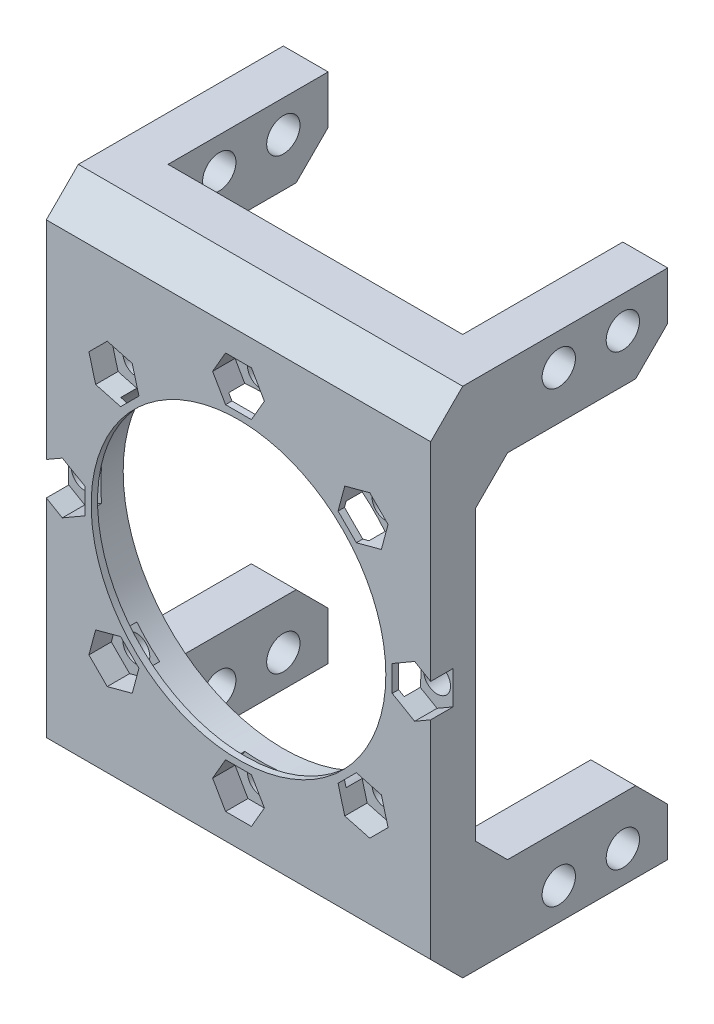
from build123d import *

# Parameters (mm, degrees)
SKETCH1_W               = 60
SKETCH1_H               = 80
BOSS_EXTRUDE1_DEPTH     = 7
SKETCH2_W               = 7
SKETCH2_H               = 12.5
BOSS_EXTRUDE2_DEPTH     = 30
SKETCH3_R               = 2.6
CUT_EXTRUDE1_DEPTH      = 50
SKETCH4_R               = 25
CUT_EXTRUDE2_DEPTH      = 107.625512894
SKETCH6_R               = 2.1
CUT_EXTRUDE3_DEPTH      = 107.625512894
MIRROR2_COPY_1_SKETCH_W = 7
MIRROR2_COPY_1_SKETCH_H = 12.5
MIRROR2_COPY_1_DEPTH    = 30
MIRROR2_COPY_2_SKETCH_R = 2.6
MIRROR2_COPY_2_DEPTH    = 50
CHAMFER1_SIZE           = 5
CHAMFER2_SIZE           = 5
SKETCH9_W               = 46
SKETCH9_H               = 7.5
BOSS_EXTRUDE4_DEPTH     = 5
CHAMFER3_SIZE           = 5
SKETCH20_R              = 25
SKETCH20_R_2            = 23
BOSS_EXTRUDE5_DEPTH     = 1
CUT_EXTRUDE5_DEPTH      = 3.5


with BuildPart() as part:
    # Sketch1 → Boss-Extrude1 (new body)
    with BuildSketch(Plane.XY):
        with Locations((30, 40)):
            Rectangle(SKETCH1_W, SKETCH1_H)
    extrude(amount=BOSS_EXTRUDE1_DEPTH)

    # Sketch2 → Boss-Extrude2 (add)
    with BuildSketch(Plane(origin=(0, 0, 0), x_dir=(-1, 0, 0), z_dir=(0, 0, -1))):
        with Locations((-3.5, 73.75)):
            Rectangle(SKETCH2_W, SKETCH2_H)
    boss_extrude2 = extrude(amount=BOSS_EXTRUDE2_DEPTH)

    # Sketch3 → Cut-Extrude1 (cut)
    with BuildSketch(Plane.ZY):
        with Locations((-13, 75)):
            Circle(SKETCH3_R)
        with Locations((-23, 75)):
            Circle(SKETCH3_R)
    cut_extrude1 = extrude(amount=-CUT_EXTRUDE1_DEPTH, mode=Mode.SUBTRACT)

    # Sketch4 → Cut-Extrude2 (cut, through all)
    with BuildSketch(Plane.XY.offset(7)):
        with Locations((30, 40)):
            Circle(SKETCH4_R)
    extrude(amount=-CUT_EXTRUDE2_DEPTH, mode=Mode.SUBTRACT)

    # Sketch6 → Cut-Extrude3 (cut, through all)
    with BuildSketch(Plane.XY.offset(7)):
        with Locations((30, 67.5)):
            Circle(SKETCH6_R)
        with Locations((49.445436483, 59.445436483)):
            Circle(SKETCH6_R)
        with Locations((57.5, 40)):
            Circle(SKETCH6_R)
        with Locations((49.445436483, 20.554563517)):
            Circle(SKETCH6_R)
        with Locations((30, 12.5)):
            Circle(SKETCH6_R)
        with Locations((10.554563517, 20.554563517)):
            Circle(SKETCH6_R)
        with Locations((2.5, 40)):
            Circle(SKETCH6_R)
        with Locations((10.554563517, 59.445436483)):
            Circle(SKETCH6_R)
    extrude(amount=-CUT_EXTRUDE3_DEPTH, mode=Mode.SUBTRACT)

    # Mirror1: Boss-Extrude2, Cut-Extrude1 across plane
    add(boss_extrude2.mirror(Plane(origin=(0, 40, 0), x_dir=(0, 0, 1), z_dir=(0, -1, 0))))
    add(cut_extrude1.mirror(Plane(origin=(0, 40, 0), x_dir=(0, 0, 1), z_dir=(0, -1, 0))), mode=Mode.SUBTRACT)

    # Mirror2: Boss-Extrude2, Cut-Extrude1 across plane
    add(boss_extrude2.mirror(Plane(origin=(30, 0, 0), x_dir=(0, 0, 1), z_dir=(1, 0, 0))))
    add(cut_extrude1.mirror(Plane(origin=(30, 0, 0), x_dir=(0, 0, 1), z_dir=(1, 0, 0))), mode=Mode.SUBTRACT)

    # Mirror2 copy 1 sketch → Mirror2 copy 1 (add)
    with BuildSketch(Plane(origin=(60, 80, 0), x_dir=(1, 0, 0), z_dir=(0, 0, -1))):
        with Locations((-3.5, 73.75)):
            Rectangle(MIRROR2_COPY_1_SKETCH_W, MIRROR2_COPY_1_SKETCH_H)
    extrude(amount=MIRROR2_COPY_1_DEPTH)

    # Mirror2 copy 2 sketch → Mirror2 copy 2 (cut)
    with BuildSketch(Plane(origin=(60, 80, 0), x_dir=(0, 0, 1), z_dir=(1, 0, 0))):
        with Locations((-13, 75)):
            Circle(MIRROR2_COPY_2_SKETCH_R)
        with Locations((-23, 75)):
            Circle(MIRROR2_COPY_2_SKETCH_R)
    extrude(amount=-MIRROR2_COPY_2_DEPTH, mode=Mode.SUBTRACT)

    # Chamfer1
    chamfer1_edges = [part.edges().sort_by_distance(p)[0] for p in [
        (56.5, 67.5, 0),
        (56.5, 12.5, 0),
        (3.5, 67.5, 0),
        (3.5, 12.5, 0),
    ]]
    chamfer(chamfer1_edges, length=CHAMFER1_SIZE)

    # Chamfer2
    chamfer2_edges = [part.edges().sort_by_distance(p)[0] for p in [
        (56.5, 67.5, -30),
        (56.5, 12.5, -30),
        (3.5, 67.5, -30),
        (3.5, 12.5, -30),
    ]]
    chamfer(chamfer2_edges, length=CHAMFER2_SIZE)

    # Sketch9 → Boss-Extrude4 (add)
    with BuildSketch(Plane(origin=(0, 0, 0), x_dir=(-1, 0, 0), z_dir=(0, 0, -1))):
        with Locations((-30, 76.25)):
            Rectangle(SKETCH9_W, SKETCH9_H)
        with Locations((-30, 3.75)):
            Rectangle(SKETCH9_W, SKETCH9_H)
    extrude(amount=BOSS_EXTRUDE4_DEPTH)

    # Chamfer3
    chamfer3_edges = [part.edges().sort_by_distance(p)[0] for p in [
        (30, 80, 7),
        (30, 0, 7),
    ]]
    chamfer(chamfer3_edges, length=CHAMFER3_SIZE)

    # Sketch20 → Boss-Extrude5 (add)
    with BuildSketch(Plane.XY.offset(7)):
        with Locations((30, 40)):
            Circle(SKETCH20_R)
        with Locations((30, 40)):
            Circle(SKETCH20_R_2, mode=Mode.SUBTRACT)
    extrude(amount=-BOSS_EXTRUDE5_DEPTH)

    # Sketch21 → Cut-Extrude5 (cut)
    with BuildSketch(Plane.XY.offset(7)):
        Polygon((52.303174516, 56.587698449), (53.349179233, 60.4914412), (50.4914412, 63.349179233), (46.587698449, 62.303174516), (45.541693732, 58.399431765), (48.399431765, 55.541693732), align=None)
        Polygon((34.041451884, 67.5), (32.020725942, 71), (27.979274058, 71), (25.958548116, 67.5), (27.979274058, 64), (32.020725942, 64), align=None)
        Polygon((57.5, 35.958548116), (61, 37.979274058), (61, 42.020725942), (57.5, 44.041451884), (54, 42.020725942), (54, 37.979274058), align=None)
        Polygon((46.587698449, 17.696825484), (50.4914412, 16.650820767), (53.349179233, 19.5085588), (52.303174516, 23.412301551), (48.399431765, 24.458306268), (45.541693732, 21.600568235), align=None)
        Polygon((25.958548116, 12.5), (27.979274058, 9), (32.020725942, 9), (34.041451884, 12.5), (32.020725942, 16), (27.979274058, 16), align=None)
        Polygon((7.696825484, 23.412301551), (6.650820767, 19.5085588), (9.5085588, 16.650820767), (13.412301551, 17.696825484), (14.458306268, 21.600568235), (11.600568235, 24.458306268), align=None)
        Polygon((2.5, 44.041451884), (-1, 42.020725942), (-1, 37.979274058), (2.5, 35.958548116), (6, 37.979274058), (6, 42.020725942), align=None)
        Polygon((13.412301551, 62.303174516), (9.5085588, 63.349179233), (6.650820767, 60.4914412), (7.696825484, 56.587698449), (11.600568235, 55.541693732), (14.458306268, 58.399431765), align=None)
    extrude(amount=-CUT_EXTRUDE5_DEPTH, mode=Mode.SUBTRACT)


solid = part.part
